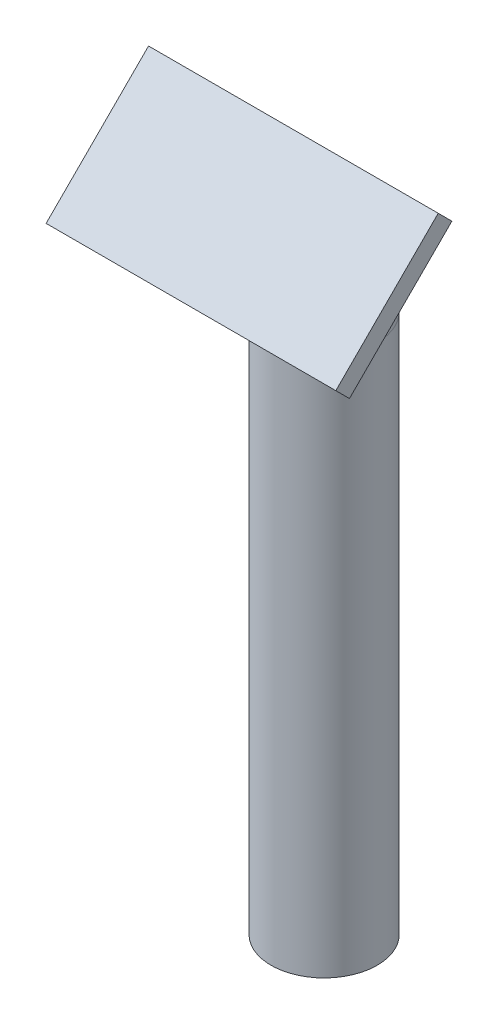
from build123d import *

# Parameters (mm, degrees)
SWEEP_THIN1_PROFILE_R   = 55
SWEEP_THIN1_PROFILE_R_2 = 53
SKETCH69_W              = 300
SKETCH69_H              = 150
BOSS_EXTRUDE1_DEPTH     = 20


with BuildPart() as part:
    # Sweep-Thin1: sweep along a path in Sketch2
    with BuildLine(Plane(origin=(0, 0, 0), x_dir=(0, 0, -1), z_dir=(1, 0, 0))) as sweep_thin1_path:
        Line((0, 0), (0, 558.578643763))
        ThreePointArc((0, 558.578643763), (-7.612046749, 596.846986999), (-29.289321881, 629.289321881))
        Line((-29.289321881, 629.289321881), (-70.710678119, 670.710678119))
    # Sweep-Thin1 profile (on start of the path) → Sweep-Thin1 (sweep)
    with BuildSketch(Plane.ZX):
        Circle(SWEEP_THIN1_PROFILE_R)
        Circle(SWEEP_THIN1_PROFILE_R_2, mode=Mode.SUBTRACT)
    sweep(path=sweep_thin1_path.line)

    # Sketch69 → Boss-Extrude1 (add)
    with BuildSketch(Plane(origin=(0, 370.710678119, 370.710678119), x_dir=(1, 0, 0), z_dir=(0, 0.7071067811865489, 0.7071067811865461))):
        with Locations((0, 424.264068712)):
            Rectangle(SKETCH69_W, SKETCH69_H)
    extrude(amount=BOSS_EXTRUDE1_DEPTH)


solid = part.part
